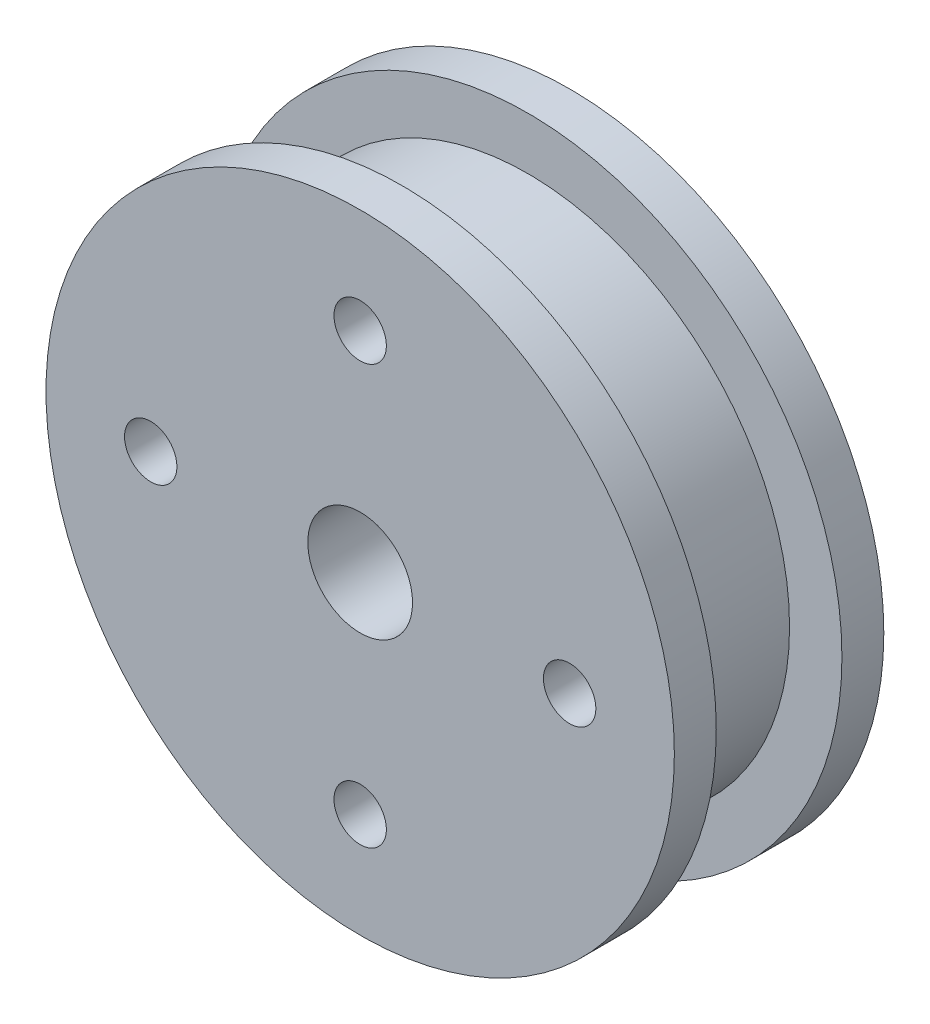
from build123d import *

# Parameters (mm, degrees)
SKETCH1_R           = 19.05
BOSS_EXTRUDE1_DEPTH = 2.54
SKETCH2_R           = 15.875
BOSS_EXTRUDE2_DEPTH = 7.62
CUT_EXTRUDE1_REACH  = 14.7
SKETCH4_R           = 3.175
CUT_EXTRUDE2_REACH  = 14.7
SKETCH5_R           = 1.5875


with BuildPart() as part:
    # Sketch1 → Boss-Extrude1 (new body)
    with BuildSketch(Plane.XY):
        Circle(SKETCH1_R)
    boss_extrude1 = extrude(amount=BOSS_EXTRUDE1_DEPTH)

    # Sketch2 → Boss-Extrude2 (add)
    with BuildSketch(Plane.XY.offset(2.54)):
        Circle(SKETCH2_R)
    extrude(amount=BOSS_EXTRUDE2_DEPTH)

    # Mirror1: Boss-Extrude1 across plane
    add(boss_extrude1.mirror(Plane.XY.offset(6.35)))

    # Sketch4 → Cut-Extrude1 (cut, up to next)
    with BuildSketch(Plane.XY.offset(12.7), mode=Mode.PRIVATE) as cut_extrude1_sk1:
        Circle(SKETCH4_R)
    cut_extrude1_tool1 = extrude(cut_extrude1_sk1.sketch, amount=-CUT_EXTRUDE1_REACH, mode=Mode.PRIVATE) & part.part
    add(cut_extrude1_tool1.solids().sort_by_distance((0, 0, 12.7))[0], mode=Mode.SUBTRACT)

    # Sketch5 → Cut-Extrude2 (cut, up to next)
    with BuildSketch(Plane(origin=(0, 0, 0), x_dir=(-1, 0, 0), z_dir=(0, 0, -1)), mode=Mode.PRIVATE) as cut_extrude2_sk1:
        with Locations((0, 12.7)):
            Circle(SKETCH5_R)
    cut_extrude2_tool1 = extrude(cut_extrude2_sk1.sketch, amount=-CUT_EXTRUDE2_REACH, mode=Mode.PRIVATE) & part.part
    add(cut_extrude2_tool1.solids().sort_by_distance((0, 12.7, 0))[0], mode=Mode.SUBTRACT)
    # Sketch5 → Cut-Extrude2 (cut, up to next)
    with BuildSketch(Plane(origin=(0, 0, 0), x_dir=(-1, 0, 0), z_dir=(0, 0, -1)), mode=Mode.PRIVATE) as cut_extrude2_sk2:
        with Locations((12.7, 0)):
            Circle(SKETCH5_R)
    cut_extrude2_tool2 = extrude(cut_extrude2_sk2.sketch, amount=-CUT_EXTRUDE2_REACH, mode=Mode.PRIVATE) & part.part
    add(cut_extrude2_tool2.solids().sort_by_distance((-12.7, 0, 0))[0], mode=Mode.SUBTRACT)
    # Sketch5 → Cut-Extrude2 (cut, up to next)
    with BuildSketch(Plane(origin=(0, 0, 0), x_dir=(-1, 0, 0), z_dir=(0, 0, -1)), mode=Mode.PRIVATE) as cut_extrude2_sk3:
        with Locations((0, -12.7)):
            Circle(SKETCH5_R)
    cut_extrude2_tool3 = extrude(cut_extrude2_sk3.sketch, amount=-CUT_EXTRUDE2_REACH, mode=Mode.PRIVATE) & part.part
    add(cut_extrude2_tool3.solids().sort_by_distance((0, -12.7, 0))[0], mode=Mode.SUBTRACT)
    # Sketch5 → Cut-Extrude2 (cut, up to next)
    with BuildSketch(Plane(origin=(0, 0, 0), x_dir=(-1, 0, 0), z_dir=(0, 0, -1)), mode=Mode.PRIVATE) as cut_extrude2_sk4:
        with Locations((-12.7, 0)):
            Circle(SKETCH5_R)
    cut_extrude2_tool4 = extrude(cut_extrude2_sk4.sketch, amount=-CUT_EXTRUDE2_REACH, mode=Mode.PRIVATE) & part.part
    add(cut_extrude2_tool4.solids().sort_by_distance((12.7, 0, 0))[0], mode=Mode.SUBTRACT)


solid = part.part
